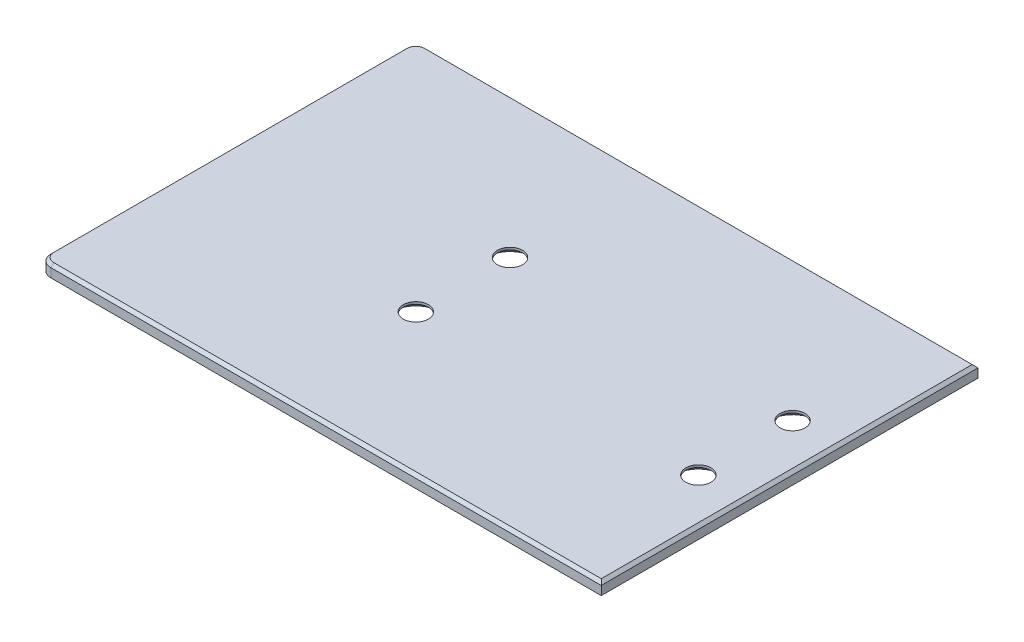
from build123d import *

# Parameters (mm, degrees)
SKETCH2_W                                   = 151.60625
SKETCH2_H                                   = 3.175
BOSS_EXTRUDE2_DEPTH                         = 101.6
CSK_FOR_1_4_FLAT_HEAD_MACHINE_SCREW_2_COUNT = 2
CSK_FOR_1_4_FLAT_HEAD_MACHINE_SCREW_2_PITCH = 25.4
CSK_FOR_1_4_FLAT_HEAD_MACHINE_SCREW_3_COUNT = 2
CSK_FOR_1_4_FLAT_HEAD_MACHINE_SCREW_3_PITCH = 80.321852568
CSK_FOR_1_4_FLAT_HEAD_MACHINE_SCREW_4_COUNT = 2
CSK_FOR_1_4_FLAT_HEAD_MACHINE_SCREW_4_PITCH = 76.2
CUT_EXTRUDE1_DEPTH                          = 4.175
CHAMFER1_SIZE                               = 0.7874


with BuildPart() as part:
    # Sketch2 → Boss-Extrude2 (new body)
    with BuildSketch(Plane.XY):
        with Locations((75.803125, -1.5875)):
            Rectangle(SKETCH2_W, SKETCH2_H)
    extrude(amount=-BOSS_EXTRUDE2_DEPTH)

    # Sketch4 → CSK for 1/4 Flat Head Machine Screw (100)1 (revolve, cut)
    with BuildSketch(Plane(origin=(63.5, -3.175, -38.1), x_dir=(0, 0, -1), z_dir=(1, 0, 0))):
        Polygon((0, 0), (0, 3.175), (3.3782, 3.175), (3.3782, 2.568232241), (6.4389, 0), align=None)
    csk_for_1_4_flat_head_machine_screw_100 = revolve(axis=Axis((63.5, -9.525, -38.1), (0, 1, 0)), mode=Mode.SUBTRACT)

    # CSK for 1_4 Flat Head Machine Screw  2: CSK for 1/4 Flat Head Machine Screw (100)1 ×2
    with Locations(*[(0, 0, -i * CSK_FOR_1_4_FLAT_HEAD_MACHINE_SCREW_2_PITCH) for i in range(1, CSK_FOR_1_4_FLAT_HEAD_MACHINE_SCREW_2_COUNT)]):
        add(csk_for_1_4_flat_head_machine_screw_100, mode=Mode.SUBTRACT)

    # CSK for 1_4 Flat Head Machine Screw  3: CSK for 1/4 Flat Head Machine Screw (100)1 ×2
    with Locations(*[Vector(0.948683298, 0, -0.316227766) * (i * CSK_FOR_1_4_FLAT_HEAD_MACHINE_SCREW_3_PITCH) for i in range(1, CSK_FOR_1_4_FLAT_HEAD_MACHINE_SCREW_3_COUNT)]):
        add(csk_for_1_4_flat_head_machine_screw_100, mode=Mode.SUBTRACT)

    # CSK for 1_4 Flat Head Machine Screw  4: CSK for 1/4 Flat Head Machine Screw (100)1 ×2
    with Locations(*[(i * CSK_FOR_1_4_FLAT_HEAD_MACHINE_SCREW_4_PITCH, 0, 0) for i in range(1, CSK_FOR_1_4_FLAT_HEAD_MACHINE_SCREW_4_COUNT)]):
        add(csk_for_1_4_flat_head_machine_screw_100, mode=Mode.SUBTRACT)

    # Sketch5 → Cut-Extrude1 (cut, through all)
    with BuildSketch(Plane.XZ.offset(3.175)):
        with BuildLine():
            Line((3.175, 0), (0, 0))
            Line((0, 0), (0, -3.175))
            ThreePointArc((0, -3.175), (0.92993597, -0.92993597), (3.175, 0))
        make_face()
        with BuildLine():
            Line((0, -101.6), (0, -98.425))
            ThreePointArc((0, -98.425), (0.92993597, -100.67006403), (3.175, -101.6))
            Line((3.175, -101.6), (0, -101.6))
        make_face()
    extrude(amount=-CUT_EXTRUDE1_DEPTH, mode=Mode.SUBTRACT)

    # Chamfer1
    chamfer1_edges = [part.edges().sort_by_distance(p)[0] for p in [
        (77.390625, 0, -101.6),
        (77.390625, 0, 0),
        (0, 0, -50.8),
        (0.92993597, 0, -0.92993597),
        (151.60625, 0, -50.8),
        (0.92993597, 0, -100.67006403),
    ]]
    chamfer(chamfer1_edges, length=CHAMFER1_SIZE)


solid = part.part
